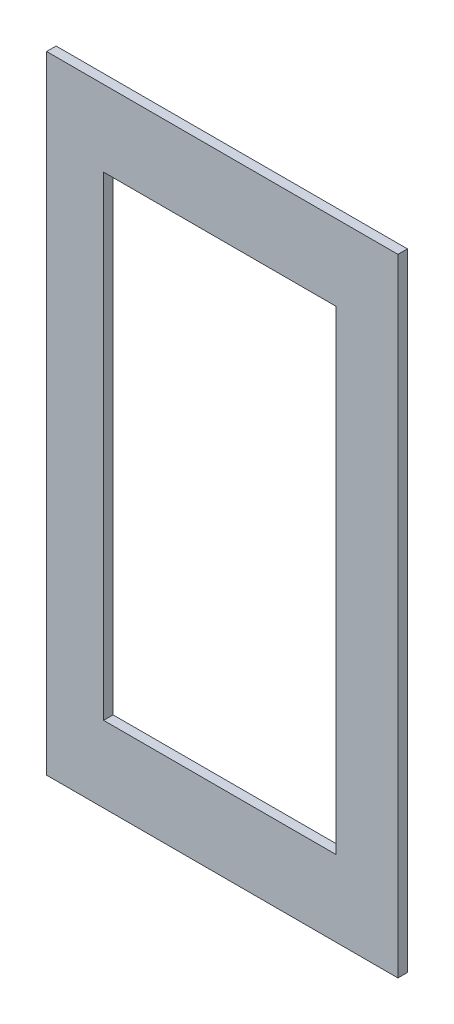
from build123d import *

# Parameters (mm, degrees)
CROQUIS2_W              = 234.95
CROQUIS2_H              = 6.35
SALIENTE_EXTRUIR1_DEPTH = 419.1
CROQUIS7_W              = 155.575
CROQUIS7_H              = 317.5
CORTAR_EXTRUIR3_DEPTH   = 6.35


with BuildPart() as part:
    # Croquis2 → Saliente-Extruir1 (new body)
    with BuildSketch(Plane(origin=(0, 0, 0), x_dir=(1, 0, 0), z_dir=(0, 1, 0))):
        Rectangle(CROQUIS2_W, CROQUIS2_H)
    extrude(amount=SALIENTE_EXTRUIR1_DEPTH)

    # Croquis7 → Cortar-Extruir3 (cut)
    with BuildSketch(Plane.XY.offset(3.175)):
        with Locations((-1.5875, 209.55)):
            Rectangle(CROQUIS7_W, CROQUIS7_H)
    extrude(amount=-CORTAR_EXTRUIR3_DEPTH, mode=Mode.SUBTRACT)


solid = part.part
